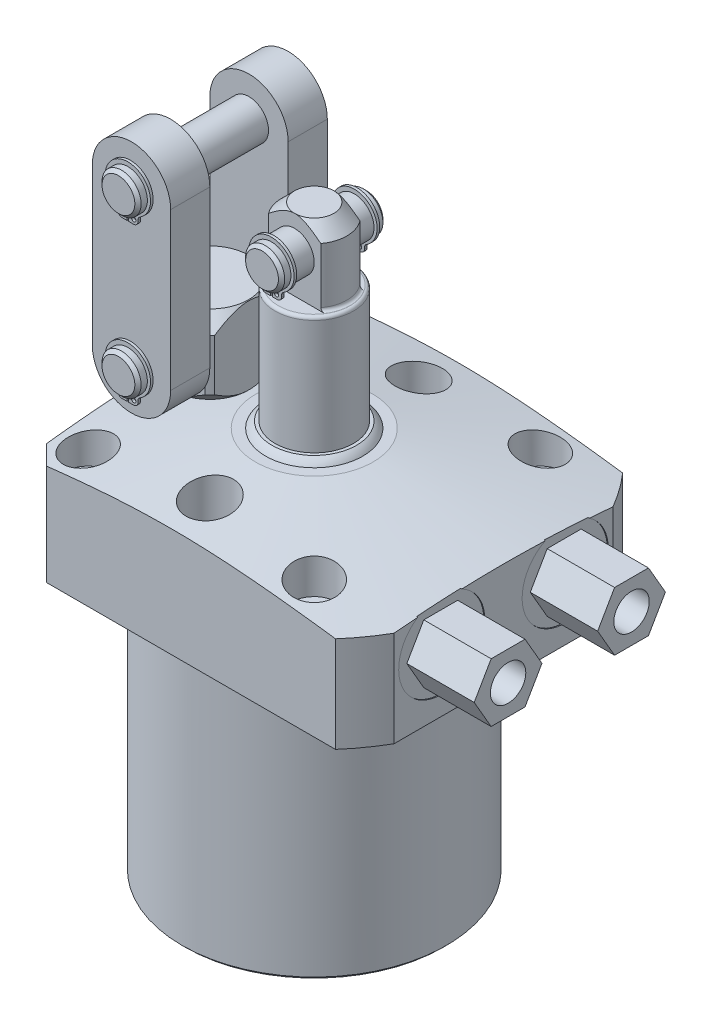
from build123d import *

# Parameters (mm, degrees)
SKETCH3_OUTSIDE_W          = 143.784
SKETCH3_OUTSIDE_H          = 143.784
SKETCH3_OUTSIDE_W_2        = 80.9498
SKETCH3_OUTSIDE_H_2        = 69.85
CUT_EXTRUDE9_DEPTH         = 93.6498
CHAMFER8_SIZE              = 4.7498
CHAMFER5_SIZE              = 0.762
HOLE1_D                    = 7.1374
HOLE1_DEPTH                = 30.1498
HOLE1_CBORE_D              = 11.0998
HOLE1_CBORE_DEPTH          = 11.9126
SKETCH34_R                 = 5.7531
CUT_EXTRUDE10_DEPTH        = 15.875
EXTRUDE14_DEPTH            = 16.383
HOLE2_D                    = 8.6106
HOLE2_DEPTH                = 6.7056
SKETCH33_R                 = 0.889
CUT_EXTRUDE7_DEPTH         = 17.4498
FILLET4_R                  = 0.762
SKETCH29_R                 = 4.75234
EXTRUDE11_DEPTH            = 12.7
EXTRUDE2_START             = -2.286
SKETCH16_R                 = 0.5207
EXTRUDE2_DEPTH             = 0.635
CHAMFER6_SIZE              = 0.762
CUT_EXTRUDE11_REACH        = 114.7
SKETCH30_R                 = 4.75234
EXTRUDE12_DEPTH            = 22.225
EXTRUDE4_START             = -2.286
SKETCH19_R                 = 0.5207
EXTRUDE4_DEPTH             = 0.635
EXTRUDE13_DEPTH            = 9.525
CHAMFER7_SIZE              = 0.762
LPATTERN2_COUNT            = 2
LPATTERN2_PITCH            = 38.1
LPATTERN2_START            = -2.286
LPATTERN2_COPY_1_SKETCH_R  = 0.5207
LPATTERN2_COPY_1_DEPTH     = 0.635
CHAMFER7_OF_LPATTERN2_SIZE = 0.762


with BuildPart() as part:
    # Sketch28 → Revolve7 (revolve)
    with BuildSketch(Plane.XY, mode=Mode.PRIVATE) as revolve7_sk:
        Polygon((-14.2875, 30.1498), (-53.1749, 23.29290217), (-53.1749, 0), (-32.1437, 0), (-32.1437, -63.5), (0, -63.5), (0, 30.1498), align=None)
    revolve(revolve7_sk.sketch.rotate(Axis((0, 0, 0), (0, 1, 0)), 270), axis=Axis((0, 0, 0), (0, 1, 0)))  # turned: the seam where the file's is

    # Sketch3 outside → Cut-Extrude9 (cut)
    with BuildSketch(Plane(origin=(0, 30.1498, 0), x_dir=(-1, 0, 0), z_dir=(0, 1, 0))):
        Rectangle(SKETCH3_OUTSIDE_W, SKETCH3_OUTSIDE_H)
        with Locations((-5.5499, 0)):
            Rectangle(SKETCH3_OUTSIDE_W_2, SKETCH3_OUTSIDE_H_2, mode=Mode.SUBTRACT)
    extrude(amount=-CUT_EXTRUDE9_DEPTH, mode=Mode.SUBTRACT)

    # Chamfer8
    chamfer8_edges = [part.edges().sort_by_distance(p)[0] for p in [
        (-34.925, 11.980016887, -34.925),
        (-34.925, 11.980016887, 34.925),
    ]]
    chamfer(chamfer8_edges, length=CHAMFER8_SIZE)

    # Chamfer5
    chamfer5_edges = [part.edges().sort_by_distance(p)[0] for p in [
        (0, -63.5, 32.1437),
    ]]
    chamfer(chamfer5_edges, length=CHAMFER5_SIZE)

    # Hole1
    with Locations(Plane(origin=(0, 30.1498, 0), x_dir=(-1, 0, 0), z_dir=(0, 1, 0))):
        with Locations((-27.4955, -27.4955), (-27.4955, 27.4955), (27.4955, -27.4955), (27.4955, 27.4955)):
            CounterBoreHole(HOLE1_D / 2, HOLE1_CBORE_D / 2, HOLE1_CBORE_DEPTH, depth=HOLE1_DEPTH)

    # Sketch34 → Cut-Extrude10 (cut)
    with BuildSketch(Plane(origin=(0, 30.1498, 0), x_dir=(1, 0, 0), z_dir=(0, 1, 0))):
        with Locations(Location((0, 25.4, 0), (0, 0, 270))):  # turned: the seam where the file's is
            Circle(SKETCH34_R)
        with Locations(Location((0, -25.4, 0), (0, 0, 135.579018313))):  # turned: the seam where the file's is
            Circle(SKETCH34_R)
        with Locations(Location((-25.4, 0, 0), (0, 0, 270))):  # turned: the seam where the file's is
            Circle(SKETCH34_R)
    extrude(amount=-CUT_EXTRUDE10_DEPTH, mode=Mode.SUBTRACT)

    # S2D0007 → Cut-Revolve2 (revolve, cut)
    with BuildSketch(Plane.XZ.offset(-15.0876)):
        Polygon((46.0248, -15.0114), (46.0248, -25.4889), (45.7708, -25.4889), (45.7708, -21.22805), (43.7007, -20.788036662), (42.902463338, -19.9898), (31.8008, -19.9898), (28.809475494, -15.0114), align=None)
    cut_revolve2 = revolve(axis=Axis((-11.746808274, 15.0876, -15.0114), (-1, 0, 0)), mode=Mode.SUBTRACT)

    # Sketch6 → Cut-Revolve3 (revolve, cut)
    with BuildSketch(Plane.XY.offset(-15.0114), mode=Mode.PRIVATE) as cut_revolve3_sk:
        with BuildLine():
            Line((45.16755, 0), (45.16755, 1.4478))
            Line((45.16755, 1.4478), (42.10705581, 1.4478))
            ThreePointArc((42.10705581, 1.4478), (41.425454622, 0.917608896), (40.64, 0.5588))
            Line((40.64, 0.5588), (39.497, 0.5588))
            Line((39.497, 0.5588), (39.497, 0))
            Line((39.497, 0), (45.16755, 0))
        make_face()
    cut_revolve3 = revolve(cut_revolve3_sk.sketch.rotate(Axis((39.497, -21.049171587, -15.0114), (0, 1, 0)), 90), axis=Axis((39.497, -21.049171587, -15.0114), (0, 1, 0)), mode=Mode.SUBTRACT)  # turned: the seam where the file's is

    # Sketch38 → Extrude14 (add)
    with BuildSketch(Plane(origin=(45.7708, 0, 0), x_dir=(0, 0, -1), z_dir=(1, 0, 0))):
        Polygon((23.252959623, 15.0876), (19.132179811, 22.225), (10.890620189, 22.225), (6.769840377, 15.0876), (10.890620189, 7.9502), (19.132179811, 7.9502), align=None)
    extrude14 = extrude(amount=EXTRUDE14_DEPTH)

    # Hole2
    with Locations(Plane(origin=(62.1538, 0, 0), x_dir=(0, 0, -1), z_dir=(1, 0, 0))):
        with Locations((15.0114, 15.0876)):
            hole2 = Hole(HOLE2_D / 2, depth=HOLE2_DEPTH)

    # Mirror6: Cut-Revolve2, Cut-Revolve3, Extrude14, Hole2 across plane
    add(cut_revolve2.mirror(Plane.XY), mode=Mode.SUBTRACT)
    add(cut_revolve3.mirror(Plane.XY), mode=Mode.SUBTRACT)
    add(extrude14.mirror(Plane.XY))
    add(hole2.mirror(Plane.XY), mode=Mode.SUBTRACT)

    # Sketch12 → Revolve2 (revolve)
    with BuildSketch(Plane(origin=(0, 0, 0), x_dir=(-1, 0, 0), z_dir=(0, 0, -1)), mode=Mode.PRIVATE) as revolve2_sk:
        with BuildLine():
            Line((0, 30.1498), (0, 31.6738))
            Line((0, 31.6738), (10.287, 31.6738))
            ThreePointArc((10.287, 31.6738), (11.136582922, 30.999382922), (11.811, 30.1498))
            Line((11.811, 30.1498), (0, 30.1498))
        make_face()
    revolve(revolve2_sk.sketch.rotate(Axis((0, 22.10562, 0), (0, 1, 0)), 270), axis=Axis((0, 22.10562, 0), (0, 1, 0)))  # turned: the seam where the file's is

    # Sketch13 → Revolve3 (revolve)
    with BuildSketch(Plane.XY, mode=Mode.PRIVATE) as revolve3_sk:
        Polygon((0, 31.6738), (0, 77.7748), (4.7625, 77.7748), (7.9375, 74.5998), (7.9375, 60.325), (9.51865, 60.325), (9.51865, 31.6738), align=None)
    revolve(revolve3_sk.sketch.rotate(Axis((0, 23.02637, 0), (0, 1, 0)), 90), axis=Axis((0, 23.02637, 0), (0, 1, 0)))  # turned: the seam where the file's is

    # Sketch14 → Cut-Extrude7 (cut)
    with BuildSketch(Plane(origin=(0, 77.7748, 0), x_dir=(-1, 0, 0), z_dir=(0, 1, 0))):
        with BuildLine():
            Line((-6.35, 4.7625), (6.35, 4.7625))
            ThreePointArc((6.35, 4.7625), (0, 7.9375), (-6.35, 4.7625))
        make_face()
        with BuildLine():
            Line((6.35, -4.7625), (-6.35, -4.7625))
            ThreePointArc((-6.35, -4.7625), (0, -7.9375), (6.35, -4.7625))
        make_face()
    extrude(amount=-CUT_EXTRUDE7_DEPTH, mode=Mode.SUBTRACT)

    # Fillet4
    fillet4_edges = [part.edges().sort_by_distance(p)[0] for p in [
        (0, 60.325, 9.51865),
        (-7.9375, 60.325, 0),
        (7.9375, 60.325, 0),
    ]]
    fillet(fillet4_edges, radius=FILLET4_R)

    # Sketch29 → Extrude11 (add, symmetric)
    with BuildSketch(Plane.XY):
        with Locations((0, 69.85)):
            Circle(SKETCH29_R)
    extrude(amount=EXTRUDE11_DEPTH, both=True)

    # Sketch16 → Extrude2 (add)
    with BuildSketch(Plane(origin=(0, 52.3748, 12.7), x_dir=(1, 0, 0), z_dir=(0, 0, 1)).offset(EXTRUDE2_START)):
        with BuildLine():
            Line((0.20828, 13.009654613), (0.20828, 10.774454613))
            Line((0.20828, 10.774454613), (1.40208, 10.774454613))
            ThreePointArc((1.40208, 10.774454613), (2.138461002, 11.079473611), (2.44348, 11.815854613))
            Line((2.44348, 11.815854613), (2.44348, 12.16672148))
            ThreePointArc((2.44348, 12.16672148), (2.57349644, 12.670600399), (2.93108124, 13.048663027))
            ThreePointArc((2.93108124, 13.048663027), (0, 23.2283), (-2.93108124, 13.048663027))
            ThreePointArc((-2.93108124, 13.048663027), (-2.57349644, 12.670600399), (-2.44348, 12.16672148))
            Line((-2.44348, 12.16672148), (-2.44348, 11.815854613))
            ThreePointArc((-2.44348, 11.815854613), (-2.138461002, 11.079473611), (-1.40208, 10.774454613))
            Line((-1.40208, 10.774454613), (-0.20828, 10.774454613))
            Line((-0.20828, 10.774454613), (-0.20828, 13.009654613))
            ThreePointArc((-0.20828, 13.009654613), (0, 21.9456), (0.20828, 13.009654613))
        make_face()
        with Locations((1.2446, 11.815854613)):
            Circle(SKETCH16_R, mode=Mode.SUBTRACT)
        with Locations(Location((-1.2446, 11.815854613, 0), (0, 0, 180))):  # turned: the seam where the file's is
            Circle(SKETCH16_R, mode=Mode.SUBTRACT)
    extrude2 = extrude(amount=-EXTRUDE2_DEPTH)

    # Chamfer6
    chamfer6_edges = [part.edges().sort_by_distance(p)[0] for p in [
        (-4.75234, 69.85, -12.7),
        (-4.75234, 69.85, 12.7),
    ]]
    chamfer(chamfer6_edges, length=CHAMFER6_SIZE)

    # Mirror2: Extrude2 across plane
    add(extrude2.mirror(Plane.XY))

    # Sketch35 → Revolve10 (revolve)
    with BuildSketch(Plane.XY, mode=Mode.PRIVATE) as revolve10_sk:
        Polygon((-25.4, 14.2748), (-19.05, 14.2748), (-19.05, 30.1498), (-16.002, 30.1498), (-12.7, 33.4518), (-12.7, 45.8978), (-16.002, 49.1998), (-25.4, 49.1998), align=None)
    revolve(revolve10_sk.sketch.rotate(Axis((-25.4, 43.57409058, 0), (0, -1, 0)), 180), axis=Axis((-25.4, 43.57409058, 0), (0, -1, 0)))  # turned: the seam where the file's is

    # Cut-Extrude11: up to this cone (the profile starts inside it)
    cut_extrude11_end = Plane(origin=(-25.4, 49.1998, 0), z_dir=(0, 1, 0)).offset(-28.447999) * Cone(1e-06, 172.096, 172.095999, align=(Align.CENTER, Align.CENTER, Align.MIN), mode=Mode.PRIVATE)
    # Sketch36 → Cut-Extrude11 (cut, up to the surface)
    with BuildSketch(Plane(origin=(0, 49.1998, 0), x_dir=(1, 0, 0), z_dir=(0, 1, 0)), mode=Mode.PRIVATE) as cut_extrude11_sk1:
        with BuildLine():
            Line((-33.800260413, 9.525), (-16.999739587, 9.525))
            ThreePointArc((-16.999739587, 9.525), (-25.4, 12.7), (-33.800260413, 9.525))
        make_face()
    cut_extrude11_tool1 = extrude(cut_extrude11_sk1.sketch, amount=-CUT_EXTRUDE11_REACH, mode=Mode.PRIVATE) & cut_extrude11_end
    add(cut_extrude11_tool1.solids().sort_by_distance((-25.4, 49.1998, -10.809673))[0], mode=Mode.SUBTRACT)
    # Sketch36 → Cut-Extrude11 (cut, up to the surface)
    with BuildSketch(Plane(origin=(0, 49.1998, 0), x_dir=(1, 0, 0), z_dir=(0, 1, 0)), mode=Mode.PRIVATE) as cut_extrude11_sk2:
        with BuildLine():
            Line((-34.925, 8.400260413), (-34.925, -8.400260413))
            ThreePointArc((-34.925, -8.400260413), (-38.1, 0), (-34.925, 8.400260413))
        make_face()
    cut_extrude11_tool2 = extrude(cut_extrude11_sk2.sketch, amount=-CUT_EXTRUDE11_REACH, mode=Mode.PRIVATE) & cut_extrude11_end
    add(cut_extrude11_tool2.solids().sort_by_distance((-36.209673, 49.1998, 0))[0], mode=Mode.SUBTRACT)
    # Sketch36 → Cut-Extrude11 (cut, up to the surface)
    with BuildSketch(Plane(origin=(0, 49.1998, 0), x_dir=(1, 0, 0), z_dir=(0, 1, 0)), mode=Mode.PRIVATE) as cut_extrude11_sk3:
        with BuildLine():
            Line((-33.800260413, -9.525), (-16.999739587, -9.525))
            ThreePointArc((-16.999739587, -9.525), (-25.4, -12.7), (-33.800260413, -9.525))
        make_face()
    cut_extrude11_tool3 = extrude(cut_extrude11_sk3.sketch, amount=-CUT_EXTRUDE11_REACH, mode=Mode.PRIVATE) & cut_extrude11_end
    add(cut_extrude11_tool3.solids().sort_by_distance((-25.4, 49.1998, 10.809673))[0], mode=Mode.SUBTRACT)
    # Sketch36 → Cut-Extrude11 (cut, up to the surface)
    with BuildSketch(Plane(origin=(0, 49.1998, 0), x_dir=(1, 0, 0), z_dir=(0, 1, 0)), mode=Mode.PRIVATE) as cut_extrude11_sk4:
        with BuildLine():
            Line((-15.875, 8.400260413), (-15.875, -8.400260413))
            ThreePointArc((-15.875, -8.400260413), (-12.7, 0), (-15.875, 8.400260413))
        make_face()
    cut_extrude11_tool4 = extrude(cut_extrude11_sk4.sketch, amount=-CUT_EXTRUDE11_REACH, mode=Mode.PRIVATE) & cut_extrude11_end
    add(cut_extrude11_tool4.solids().sort_by_distance((-14.590327, 49.1998, 0))[0], mode=Mode.SUBTRACT)

    # Sketch30 → Extrude12 (add, symmetric)
    with BuildSketch(Plane.XY):
        with Locations((-25.4, 39.6748)):
            Circle(SKETCH30_R)
    extrude12 = extrude(amount=EXTRUDE12_DEPTH, both=True)

    # Sketch19 → Extrude4 (add)
    with BuildSketch(Plane(origin=(-22.225, 11.0998, 22.225), x_dir=(1, 0, 0), z_dir=(0, 0, 1)).offset(EXTRUDE4_START)):
        with BuildLine():
            Line((-2.96672, 24.109454613), (-2.96672, 21.874254613))
            Line((-2.96672, 21.874254613), (-1.77292, 21.874254613))
            ThreePointArc((-1.77292, 21.874254613), (-1.036538998, 22.179273611), (-0.73152, 22.915654613))
            Line((-0.73152, 22.915654613), (-0.73152, 23.26652148))
            ThreePointArc((-0.73152, 23.26652148), (-0.60150356, 23.770400399), (-0.24391876, 24.148463027))
            ThreePointArc((-0.24391876, 24.148463027), (-3.175, 34.3281), (-6.10608124, 24.148463027))
            ThreePointArc((-6.10608124, 24.148463027), (-5.74849644, 23.770400399), (-5.61848, 23.26652148))
            Line((-5.61848, 23.26652148), (-5.61848, 22.915654613))
            ThreePointArc((-5.61848, 22.915654613), (-5.313461002, 22.179273611), (-4.57708, 21.874254613))
            Line((-4.57708, 21.874254613), (-3.38328, 21.874254613))
            Line((-3.38328, 21.874254613), (-3.38328, 24.109454613))
            ThreePointArc((-3.38328, 24.109454613), (-3.175, 33.0454), (-2.96672, 24.109454613))
        make_face()
        with Locations((-1.72212, 22.915654613)):
            Circle(SKETCH19_R, mode=Mode.SUBTRACT)
        with Locations(Location((-4.62788, 22.915654613, 0), (0, 0, 180))):  # turned: the seam where the file's is
            Circle(SKETCH19_R, mode=Mode.SUBTRACT)
    extrude4 = extrude(amount=-EXTRUDE4_DEPTH)

    # Sketch37 → Extrude13 (add)
    with BuildSketch(Plane.XY.offset(9.525)):
        with BuildLine():
            Line((-34.924999877, 77.774800031), (-34.925, 39.674800031))
            ThreePointArc((-34.925, 39.674800031), (-25.400000031, 30.1498), (-15.875, 39.674799969))
            Line((-15.875, 39.674799969), (-15.874999877, 77.774799969))
            ThreePointArc((-15.874999877, 77.774799969), (-25.399999847, 87.2998), (-34.924999877, 77.774800031))
        make_face()
    extrude13 = extrude(amount=EXTRUDE13_DEPTH)

    # Mirror3: Extrude4 across plane
    add(extrude4.mirror(Plane.XY))

    # Chamfer7
    chamfer7_edges = [part.edges().sort_by_distance(p)[0] for p in [
        (-30.15234, 39.6748, -22.225),
        (-30.15234, 39.6748, 22.225),
    ]]
    chamfer(chamfer7_edges, length=CHAMFER7_SIZE)

    # LPattern2: Extrude4, Extrude12 ×2
    with Locations(*[(0, i * LPATTERN2_PITCH, 0) for i in range(1, LPATTERN2_COUNT)]):
        add(extrude4)
        add(extrude12)

    # LPattern2 copy 1 sketch → LPattern2 copy 1 (add)
    with BuildSketch(Plane(origin=(-22.224999877, 49.1998, -22.225), x_dir=(1, 0, 0), z_dir=(0, 0, -1)).offset(LPATTERN2_START)):
        with BuildLine():
            Line((-2.96672, -24.109454613), (-2.96672, -21.874254613))
            Line((-2.96672, -21.874254613), (-1.77292, -21.874254613))
            ThreePointArc((-1.77292, -21.874254613), (-1.036538998, -22.179273611), (-0.73152, -22.915654613))
            Line((-0.73152, -22.915654613), (-0.73152, -23.26652148))
            ThreePointArc((-0.73152, -23.26652148), (-0.60150356, -23.770400399), (-0.24391876, -24.148463027))
            ThreePointArc((-0.24391876, -24.148463027), (-3.175, -34.3281), (-6.10608124, -24.148463027))
            ThreePointArc((-6.10608124, -24.148463027), (-5.74849644, -23.770400399), (-5.61848, -23.26652148))
            Line((-5.61848, -23.26652148), (-5.61848, -22.915654613))
            ThreePointArc((-5.61848, -22.915654613), (-5.313461002, -22.179273611), (-4.57708, -21.874254613))
            Line((-4.57708, -21.874254613), (-3.38328, -21.874254613))
            Line((-3.38328, -21.874254613), (-3.38328, -24.109454613))
            ThreePointArc((-3.38328, -24.109454613), (-3.175, -33.0454), (-2.96672, -24.109454613))
        make_face()
        with Locations((-1.72212, -22.915654613)):
            Circle(LPATTERN2_COPY_1_SKETCH_R, mode=Mode.SUBTRACT)
        with Locations((-4.62788, -22.915654613)):
            Circle(LPATTERN2_COPY_1_SKETCH_R, mode=Mode.SUBTRACT)
    extrude(amount=-LPATTERN2_COPY_1_DEPTH)

    # Chamfer7 of LPattern2
    chamfer7_of_lpattern2_edges = [part.edges().sort_by_distance(p)[0] for p in [
        (-30.152339877, 77.7748, -22.225),
        (-30.152339877, 77.7748, 22.225),
    ]]
    chamfer(chamfer7_of_lpattern2_edges, length=CHAMFER7_OF_LPATTERN2_SIZE)

    # Mirror8: Extrude13 across plane
    add(extrude13.mirror(Plane.XY))


with BuildPart() as body_2:
    # Sketch33 → Revolve9 (revolve)
    with BuildSketch(Plane.XY.offset(-15.0114), mode=Mode.PRIVATE) as revolve9_sk:
        with Locations((34.71545, 0.5842)):
            Circle(SKETCH33_R)
    revolve(revolve9_sk.sketch.rotate(Axis((39.497, 8.329668034, -15.0114), (0, -1, 0)), 90), axis=Axis((39.497, 8.329668034, -15.0114), (0, -1, 0)))  # turned: the seam where the file's is


with BuildPart() as body_3:
    # Mirror7: mirrored copy
    add(body_2.part.mirror(Plane.XY))


solid = Compound([part.part, body_2.part, body_3.part])
